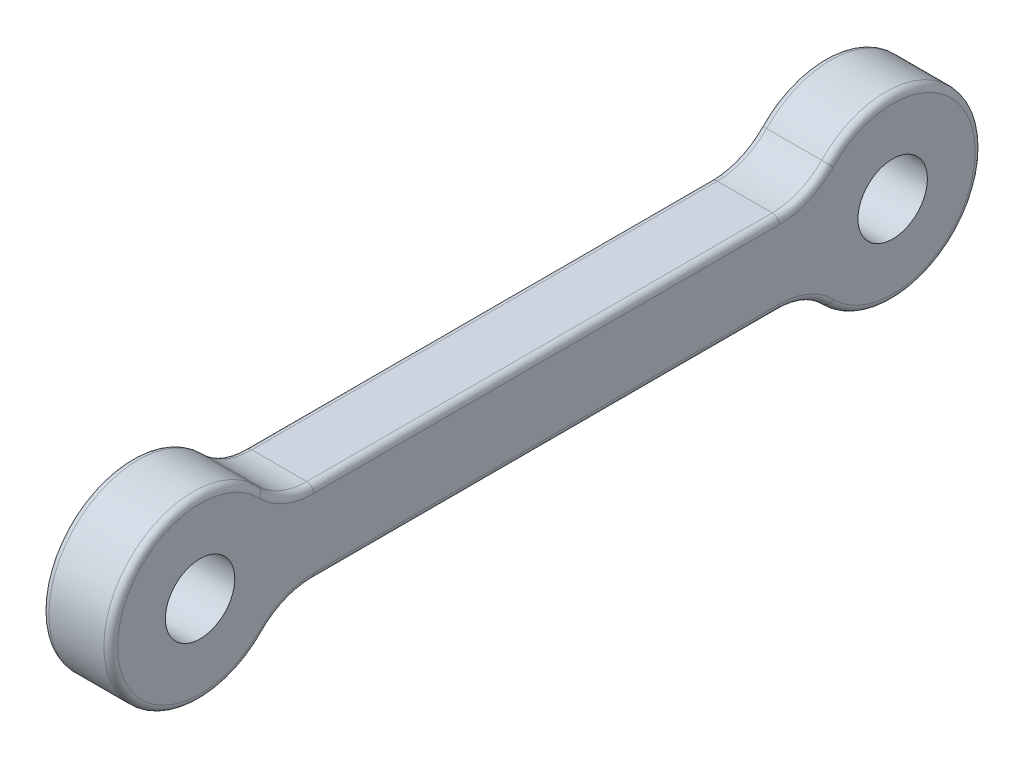
from build123d import *

# Parameters (mm, degrees)
SKETCH_1_R      = 5.05
EXTRUDE_1_DEPTH = 10
FILLET_1_R      = 1


with BuildPart() as part:
    # 草图1 → 凸台-拉伸1 (new body)
    with BuildSketch(Plane(origin=(0, 0, 0), x_dir=(0, 0, -1), z_dir=(1, 0, 0))):
        with BuildLine():
            Line((-84.227288358, 6), (-16.522711642, 6))
            ThreePointArc((-16.522711642, 6), (-12.621764154, 6.792252789), (-9.338923971, 9.043478261))
            ThreePointArc((-9.338923971, 9.043478261), (13, 0), (-9.338923971, -9.043478261))
            ThreePointArc((-9.338923971, -9.043478261), (-12.621764154, -6.792252789), (-16.522711642, -6))
            Line((-16.522711642, -6), (-84.227288358, -6))
            ThreePointArc((-84.227288358, -6), (-88.128235846, -6.792252789), (-91.411076029, -9.043478261))
            ThreePointArc((-91.411076029, -9.043478261), (-113.75, 0), (-91.411076029, 9.043478261))
            ThreePointArc((-91.411076029, 9.043478261), (-88.128235846, 6.792252789), (-84.227288358, 6))
        make_face()
        with Locations((-100.75, 0)):
            Circle(SKETCH_1_R, mode=Mode.SUBTRACT)
        Circle(SKETCH_1_R, mode=Mode.SUBTRACT)
    extrude(amount=EXTRUDE_1_DEPTH)

    # 圆角1
    fillet_1_edges = [part.edges().sort_by_distance(p)[0] for p in [
        (0, 6, 50.375),
        (0, 6.792252789, 12.621764154),
        (0, 0, -13),
        (0, -6.792252789, 12.621764154),
        (10, 6.792252789, 12.621764154),
        (10, 6, 50.375),
        (10, 6.792252789, 88.128235846),
        (10, 0, 113.75),
        (10, -6.792252789, 88.128235846),
        (10, -6, 50.375),
        (10, -6.792252789, 12.621764154),
        (0, -6, 50.375),
        (10, 0, -13),
        (0, -6.792252789, 88.128235846),
        (0, 0, 113.75),
        (0, 6.792252789, 88.128235846),
    ]]
    fillet(fillet_1_edges, radius=FILLET_1_R)


solid = part.part
